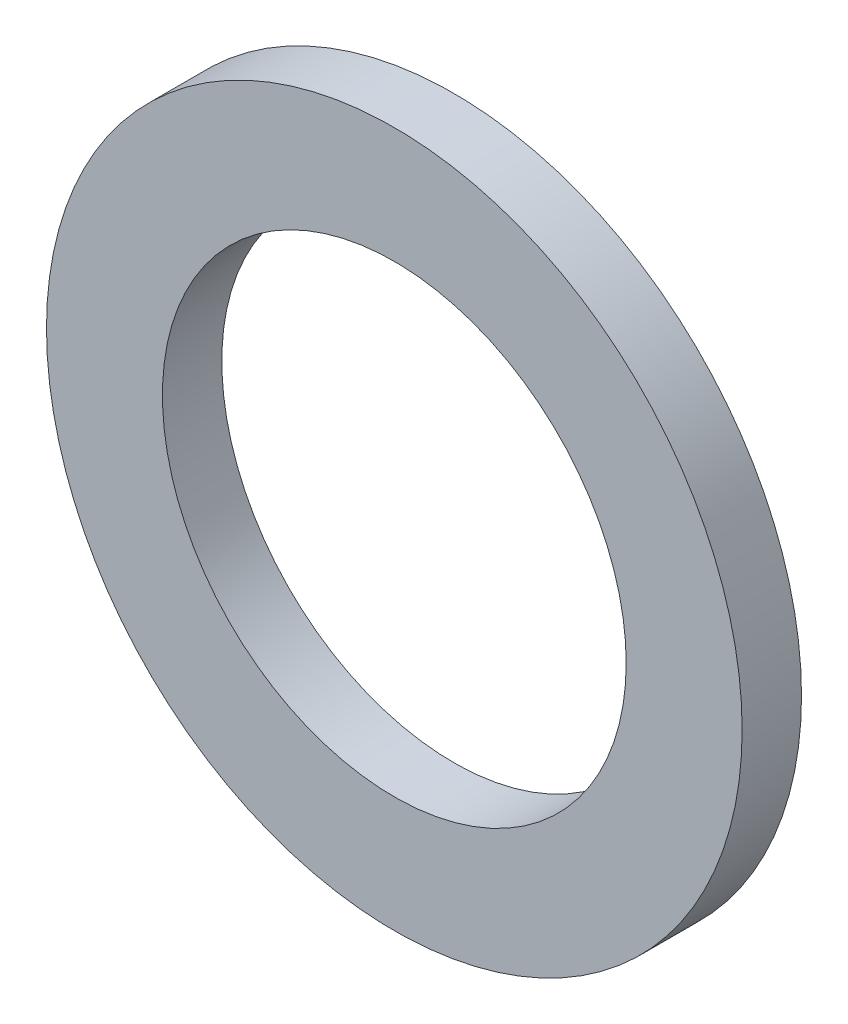
from build123d import *

# Parameters (mm, degrees)
SKETCH1_R           = 2.38125
SKETCH1_R_2         = 1.5875
BOSS_EXTRUDE1_DEPTH = 0.4064


with BuildPart() as part:
    # Sketch1 → Boss-Extrude1 (new body)
    with BuildSketch(Plane.XY):
        Circle(SKETCH1_R)
        Circle(SKETCH1_R_2, mode=Mode.SUBTRACT)
    extrude(amount=BOSS_EXTRUDE1_DEPTH)


solid = part.part
